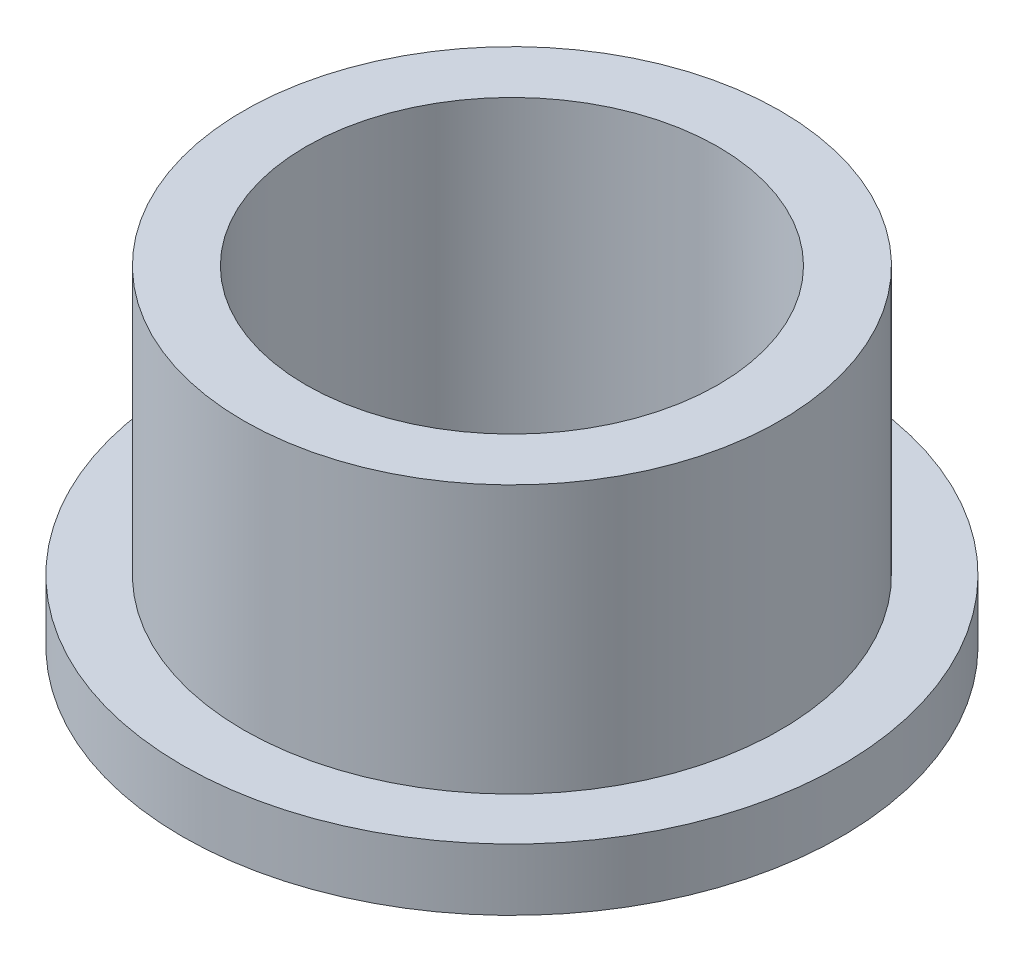
from build123d import *

# Parameters (mm, degrees)
SKETCH2_R           = 6.515
SKETCH2_R_2         = 5.005
BOSS_EXTRUDE1_DEPTH = 8
SKETCH3_R           = 8
SKETCH3_R_2         = 6.515
BOSS_EXTRUDE2_DEPTH = 1.5


with BuildPart() as part:
    # Sketch2 → Boss-Extrude1 (new body)
    with BuildSketch(Plane(origin=(0, 0, 0), x_dir=(1, 0, 0), z_dir=(0, 1, 0))):
        Circle(SKETCH2_R)
        Circle(SKETCH2_R_2, mode=Mode.SUBTRACT)
    extrude(amount=BOSS_EXTRUDE1_DEPTH)

    # Sketch3 → Boss-Extrude2 (add)
    with BuildSketch(Plane(origin=(0, 0, 0), x_dir=(1, 0, 0), z_dir=(0, 1, 0))):
        Circle(SKETCH3_R)
        Circle(SKETCH3_R_2, mode=Mode.SUBTRACT)
    extrude(amount=BOSS_EXTRUDE2_DEPTH)


solid = part.part
